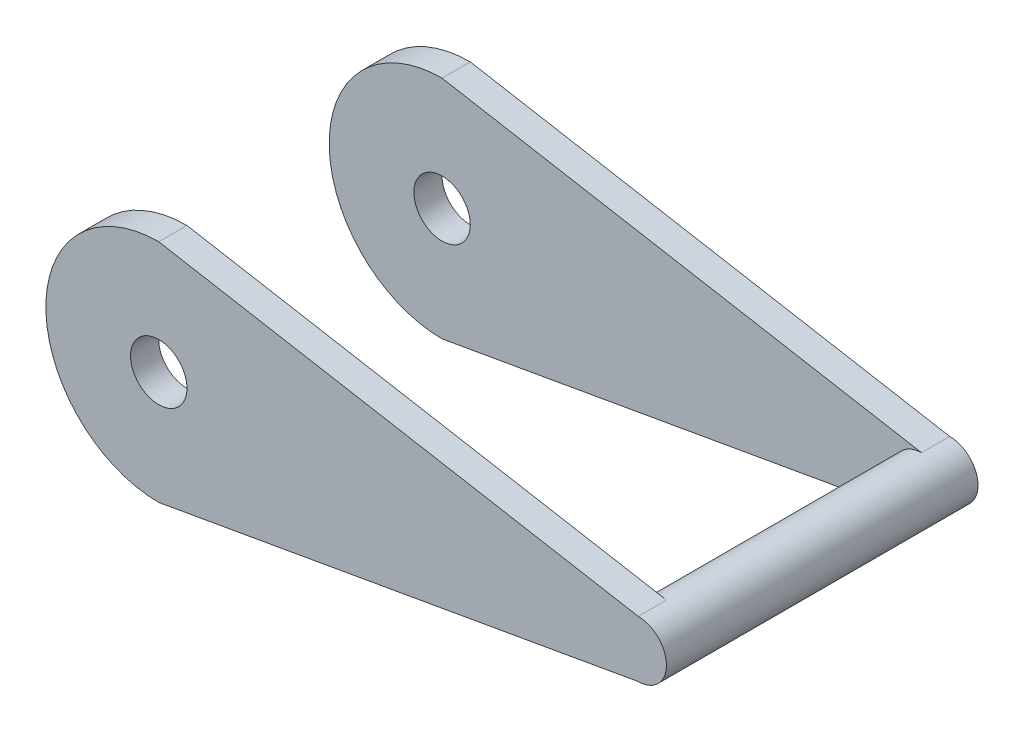
from build123d import *

# Parameters (mm, degrees)
SKETCH2_R           = 3.175
BOSS_EXTRUDE1_DEPTH = 3.175
SKETCH3_R           = 3.175
BOSS_EXTRUDE2_DEPTH = 14.351


with BuildPart() as part:
    # Sketch2 → Boss-Extrude1 (new body)
    with BuildSketch(Plane.XY.offset(17.526)):
        with BuildLine():
            ThreePointArc((238.125, 76.736249645), (225.425, 64.036249645), (238.125, 51.336249645))
            Line((238.125, 51.336249645), (242.474118596, 52.104143065))
            ThreePointArc((242.474118596, 52.104143065), (248.529898033, 56.754210308), (250.825, 64.036249645))
            ThreePointArc((250.825, 64.036249645), (248.529898033, 71.318288983), (242.474118596, 75.968356225))
            Line((242.474118596, 75.968356225), (238.125, 76.736249645))
        make_face()
        with Locations((238.125, 64.036249645)):
            Circle(SKETCH2_R, mode=Mode.SUBTRACT)
        with BuildLine():
            ThreePointArc((250.825, 64.036249645), (248.529898033, 56.754210308), (242.474118596, 52.104143065))
            Line((242.474118596, 52.104143065), (292.071750355, 60.861249645))
            ThreePointArc((292.071750355, 60.861249645), (288.896750355, 64.036249645), (292.071750355, 67.211249645))
            Line((292.071750355, 67.211249645), (242.474118596, 75.968356225))
            ThreePointArc((242.474118596, 75.968356225), (248.529898033, 71.318288983), (250.825, 64.036249645))
        make_face()
        with Locations((292.071750355, 64.036249645)):
            Circle(SKETCH2_R)
    boss_extrude1 = extrude(amount=-BOSS_EXTRUDE1_DEPTH)

    # Sketch3 → Boss-Extrude2 (add)
    with BuildSketch(Plane(origin=(0, 0, 14.351), x_dir=(-1, 0, 0), z_dir=(0, 0, -1))):
        with Locations((-292.071750355, 64.036249645)):
            Circle(SKETCH3_R)
    boss_extrude2 = extrude(amount=BOSS_EXTRUDE2_DEPTH)

    # Mirror1: Boss-Extrude1, Boss-Extrude2 across plane
    add(boss_extrude1.mirror(Plane.XY))
    add(boss_extrude2.mirror(Plane.XY))


solid = part.part
